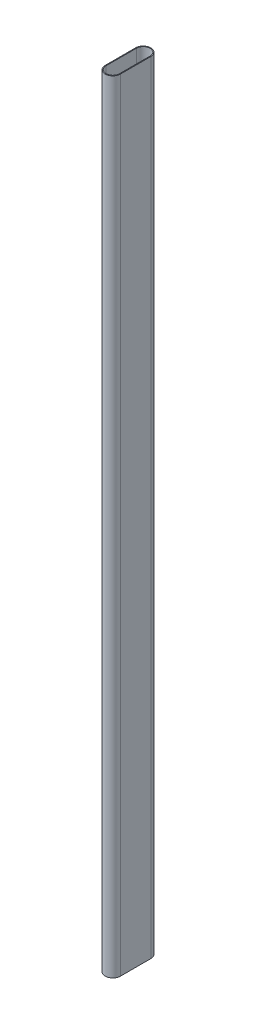
from build123d import *

# Parameters (mm, degrees)
EXTRUDE_THIN1_DEPTH = 515


with BuildPart() as part:
    # Sketch1 → Extrude-Thin1 (new body)
    with BuildSketch(Plane(origin=(0, 0, 0), x_dir=(1, 0, 0), z_dir=(0, 1, 0))):
        with BuildLine():
            Line((5, 10), (5, -10))
            ThreePointArc((5, -10), (0, -15), (-5, -10))
            Line((-5, -10), (-5, 10))
            ThreePointArc((-5, 10), (0, 15), (5, 10))
        make_face()
        with BuildLine():
            Line((4.5, 10), (4.5, -10))
            ThreePointArc((4.5, -10), (0, -14.5), (-4.5, -10))
            Line((-4.5, -10), (-4.5, 10))
            ThreePointArc((-4.5, 10), (0, 14.5), (4.5, 10))
        make_face(mode=Mode.SUBTRACT)
    extrude(amount=EXTRUDE_THIN1_DEPTH)


solid = part.part
